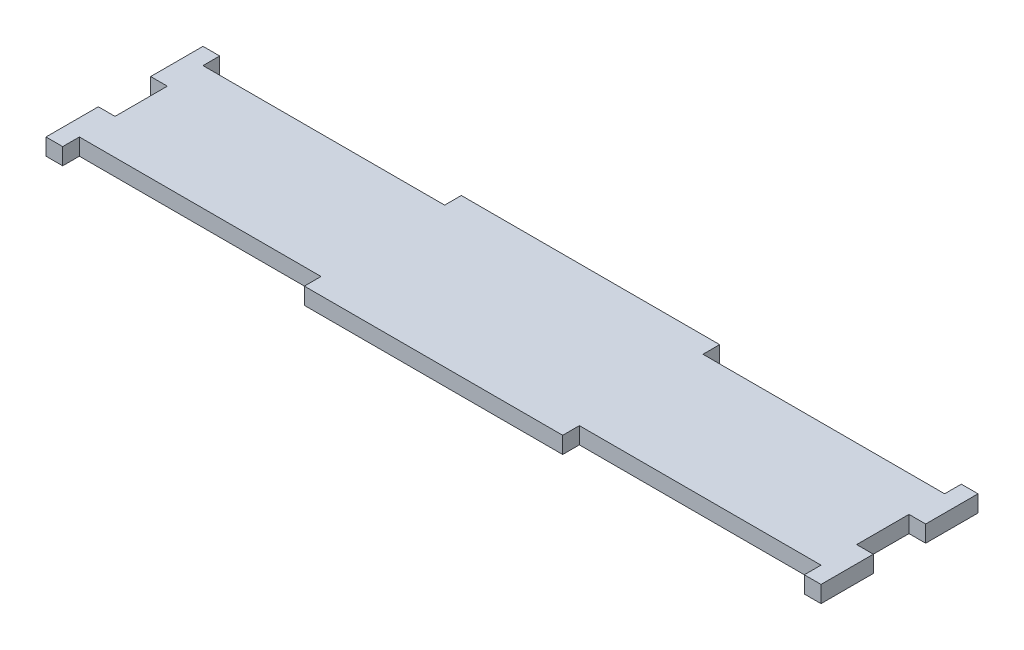
from build123d import *

# Parameters (mm, degrees)
BOSS_EXTRUDE1_DEPTH = 2.7


with BuildPart() as part:
    # Sketch1 → Boss-Extrude1 (new body)
    with BuildSketch(Plane(origin=(0, 0, 0), x_dir=(1, 0, 0), z_dir=(0, 1, 0))):
        Polygon((-62.7, 12.7), (-60, 12.7), (-60, 10), (-20.9, 10), (-20.9, 12.7), (20.9, 12.7), (20.9, 10), (60, 10), (60, 12.7), (62.7, 12.7), (62.7, 4.233333333), (60, 4.233333333), (60, -4.233333333), (62.7, -4.233333333), (62.7, -12.7), (60, -12.7), (60, -10), (20.9, -10), (20.9, -12.7), (-20.9, -12.7), (-20.9, -10), (-60, -10), (-60, -12.7), (-62.7, -12.7), (-62.7, -4.233333333), (-60, -4.233333333), (-60, 4.233333333), (-62.7, 4.233333333), align=None)
    extrude(amount=BOSS_EXTRUDE1_DEPTH)


solid = part.part
